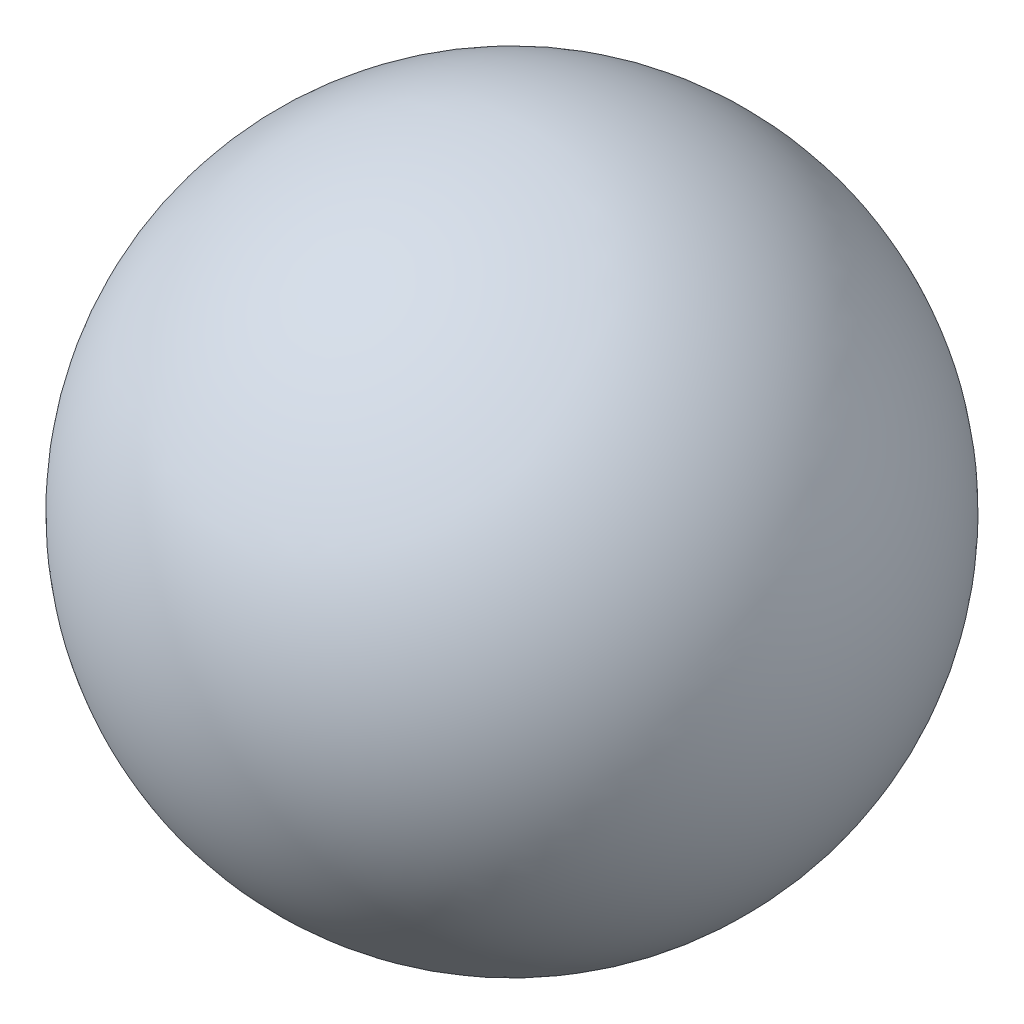
from build123d import *


with BuildPart() as part:
    # 草图1 one side → 旋转2 (revolve)
    with BuildSketch(Plane(origin=(0, 0, 0), x_dir=(1, 0, 0), z_dir=(0, 1, 0))):
        with BuildLine():
            ThreePointArc((0, -2.5), (1.767766953, -1.767766953), (2.5, 0))
            ThreePointArc((2.5, 0), (1.767766953, 1.767766953), (0, 2.5))
            Line((0, 2.5), (0, -2.5))
        make_face()
    revolve(axis=Axis((0, 0, -6.936103092), (0, 0, 1)))


solid = part.part
